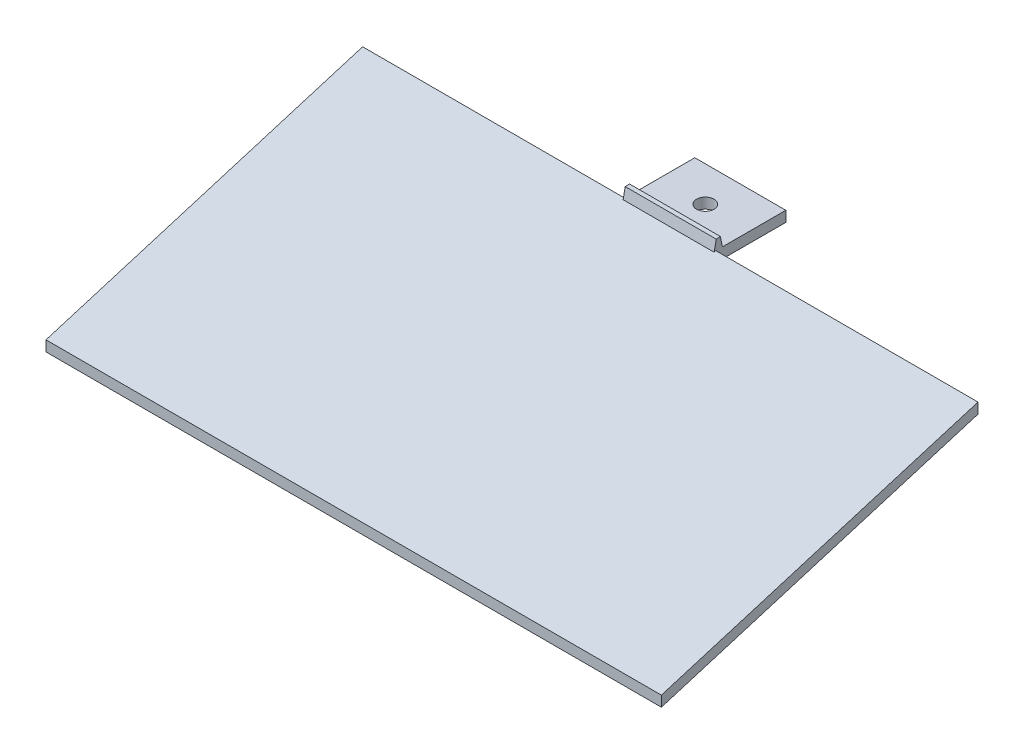
from build123d import *

# Parameters (mm, degrees)
SALIENTE_EXTRUIR1_DEPTH = 175.8
CROQUIS3_W              = 20
CROQUIS3_H              = 3
SALIENTE_EXTRUIR2_DEPTH = 175.8
CROQUIS4_W              = 74.9
CROQUIS4_H              = 20
CROQUIS4_R              = 2.5
CORTAR_EXTRUIR1_DEPTH   = 165.8
SALIENTE_EXTRUIR3_START = -26
SALIENTE_EXTRUIR3_DEPTH = 26
CORTAR_EXTRUIR2_DEPTH   = 26


with BuildPart() as part:
    # Croquis2 → Saliente-Extruir1 (new body)
    with BuildSketch(Plane(origin=(0, 0, 0), x_dir=(0, 0, -1), z_dir=(1, 0, 0))):
        Polygon((0, 27.28), (0, 30.28), (-90.45, 3), (-90.45, 0), align=None)
    extrude(amount=SALIENTE_EXTRUIR1_DEPTH)

    # Croquis3 → Saliente-Extruir2 (add)
    with BuildSketch(Plane(origin=(175.8, 0, 0), x_dir=(0, 0, -1), z_dir=(1, 0, 0))):
        with Locations((10, 28.78)):
            Rectangle(CROQUIS3_W, CROQUIS3_H)
    extrude(amount=-SALIENTE_EXTRUIR2_DEPTH)

    # Croquis4 → Cortar-Extruir1 (cut)
    with BuildSketch(Plane(origin=(0, 30.28, 0), x_dir=(1, 0, 0), z_dir=(0, 1, 0))):
        with Locations((138.35, 10)):
            Rectangle(CROQUIS4_W, CROQUIS4_H)
        with Locations((37.45, 10)):
            Rectangle(CROQUIS4_W, CROQUIS4_H)
        with Locations((87.9, 10)):
            Circle(CROQUIS4_R)
    extrude(amount=-CORTAR_EXTRUIR1_DEPTH, mode=Mode.SUBTRACT)

    # Croquis5 → Saliente-Extruir3 (add)
    with BuildSketch(Plane(origin=(100.9, 0, 0), x_dir=(0, 0, -1), z_dir=(1, 0, 0)).offset(SALIENTE_EXTRUIR3_START)):
        Polygon((1.878378592, 30.28), (0.745913837, 36.00039966), (-0.555574899, 29.798151404), align=None)
    extrude(amount=SALIENTE_EXTRUIR3_DEPTH)

    # Croquis6 → Cortar-Extruir2 (cut)
    with BuildSketch(Plane(origin=(100.9, 0, 0), x_dir=(0, 0, -1), z_dir=(1, 0, 0))):
        Polygon((0.130372487, 33.067035615), (1.312146214, 33.14019983), (0.745913837, 36.00039966), align=None)
    extrude(amount=-CORTAR_EXTRUIR2_DEPTH, mode=Mode.SUBTRACT)


solid = part.part
